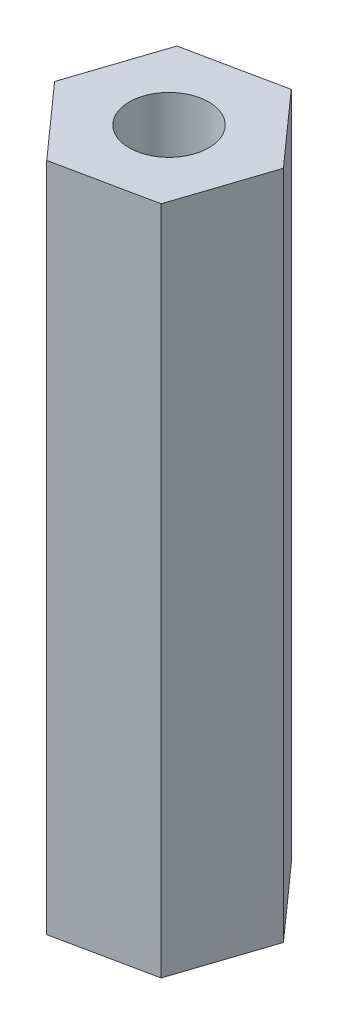
from build123d import *

# Parameters (mm, degrees)
SKETCH1_R           = 1.1303
BOSS_EXTRUDE1_DEPTH = 19.05


with BuildPart() as part:
    # Sketch1 → Boss-Extrude1 (new body)
    with BuildSketch(Plane(origin=(0, 0, 0), x_dir=(1, 0, 0), z_dir=(0, 1, 0))):
        Polygon((-5.140093993, 1.232124046), (-4.277220861, 3.842855497), (-6.106744054, 5.895491275), (-8.799140379, 5.337395601), (-9.662013511, 2.726664151), (-7.832490318, 0.674028373), align=None)
        with Locations((-6.969617186, 3.284759824)):
            Circle(SKETCH1_R, mode=Mode.SUBTRACT)
    extrude(amount=BOSS_EXTRUDE1_DEPTH)


solid = part.part
